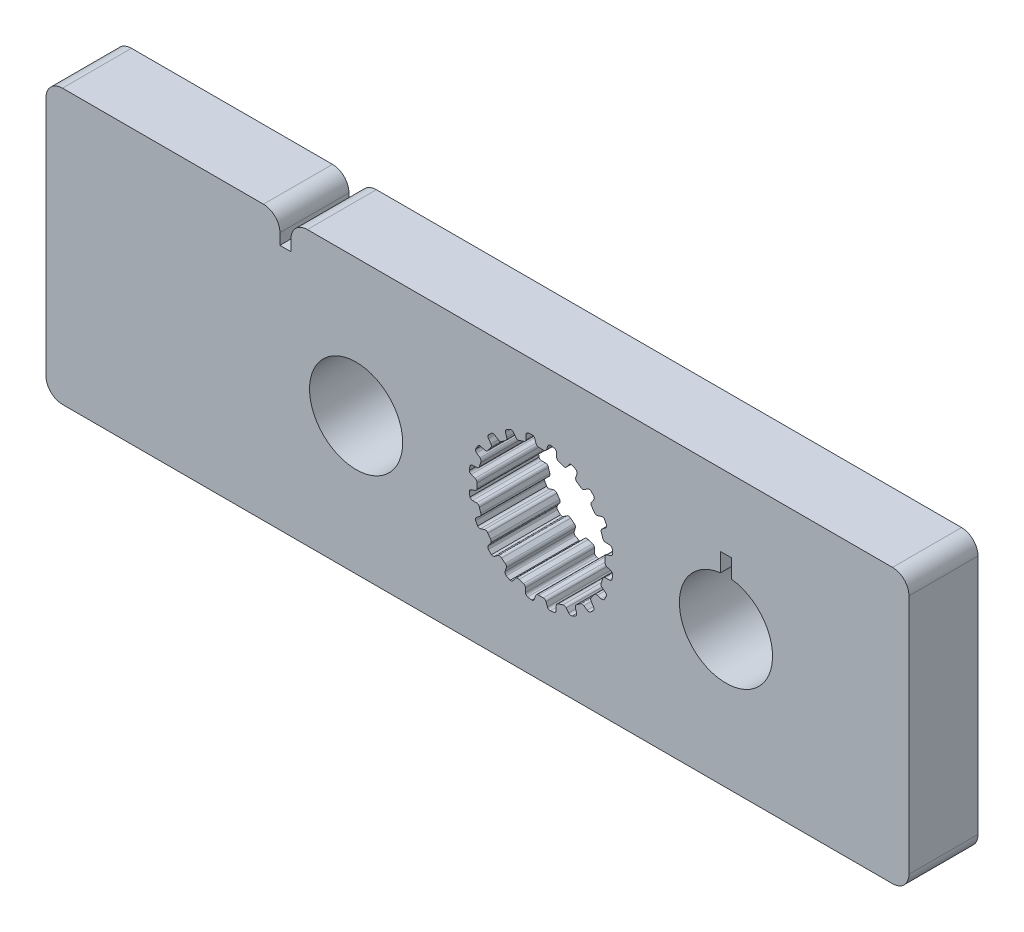
from build123d import *

# Parameters (mm, degrees)
SKETCH1_W           = 40.005
SKETCH1_H           = 12.7
SKETCH1_R           = 2.159
BOSS_EXTRUDE1_DEPTH = 1.6002
SKETCH2_W           = 0.508
SKETCH2_H           = 1.27
CUT_EXTRUDE1_DEPTH  = 3.2004
FILLET1_R           = 0.762


with BuildPart() as part:
    # Sketch1 → Boss-Extrude1 (new body, symmetric)
    with BuildSketch(Plane.XY):
        with Locations((-2.9464, 0)):
            Rectangle(SKETCH1_W, SKETCH1_H)
        with Locations((-8.5725, 0)):
            Circle(SKETCH1_R, mode=Mode.SUBTRACT)
        with Locations((8.5725, 0)):
            Circle(SKETCH1_R, mode=Mode.SUBTRACT)
        with BuildLine():
            Line((-0.106949245, 2.969874934), (0.106949245, 2.969874934))
            ThreePointArc((0.106949245, 2.969874934), (0.196343213, 2.986924176), (0.253739238, 3.057547504))
            Line((0.253739238, 3.057547504), (0.315888147, 3.237526941))
            ThreePointArc((0.315888147, 3.237526941), (0.359032156, 3.298322911), (0.4281449, 3.326269005))
            Line((0.4281449, 3.326269005), (0.620027588, 3.2937547))
            ThreePointArc((0.620027588, 3.2937547), (0.689621142, 3.24802576), (0.718272212, 3.169836791))
            Line((0.718272212, 3.169836791), (0.724389167, 2.979527391))
            ThreePointArc((0.724389167, 2.979527391), (0.750934762, 2.9040661), (0.816027049, 2.857568043))
            Line((0.816027049, 2.857568043), (1.019456602, 2.791469774))
            ThreePointArc((1.019456602, 2.791469774), (1.109743823, 2.780060312), (1.186154496, 2.829490741))
            Line((1.186154496, 2.829490741), (1.300878326, 2.981456288))
            ThreePointArc((1.300878326, 2.981456288), (1.360697704, 3.02594446), (1.435063648, 3.031165762))
            Line((1.435063648, 3.031165762), (1.607507455, 2.940947809))
            ThreePointArc((1.607507455, 2.940947809), (1.659563839, 2.875951412), (1.662650905, 2.792735615))
            Line((1.662650905, 2.792735615), (1.609659636, 2.609850378))
            ThreePointArc((1.609659636, 2.609850378), (1.611587176, 2.529879385), (1.659124931, 2.465542482))
            Line((1.659124931, 2.465542482), (1.832172444, 2.339816104))
            ThreePointArc((1.832172444, 2.339816104), (1.914514976, 2.301064775), (2.002460687, 2.32446371))
            Line((2.002460687, 2.32446371), (2.158529469, 2.433539921))
            ThreePointArc((2.158529469, 2.433539921), (2.229168681, 2.457365482), (2.301508367, 2.439350895))
            Line((2.301508367, 2.439350895), (2.437633293, 2.300260456))
            ThreePointArc((2.437633293, 2.300260456), (2.467056864, 2.222358901), (2.444277744, 2.14226202))
            Line((2.444277744, 2.14226202), (2.337365406, 1.984703026))
            ThreePointArc((2.337365406, 1.984703026), (2.314486209, 1.908050449), (2.339816104, 1.832172444))
            Line((2.339816104, 1.832172444), (2.465542482, 1.659124931))
            ThreePointArc((2.465542482, 1.659124931), (2.531880064, 1.596824985), (2.622752074, 1.591901975))
            Line((2.622752074, 1.591901975), (2.804888709, 1.64741171))
            ThreePointArc((2.804888709, 1.64741171), (2.879433095, 1.648242449), (2.942665411, 1.608755366))
            Line((2.942665411, 1.608755366), (3.0291466, 1.434407582))
            ThreePointArc((3.0291466, 1.434407582), (3.033057175, 1.351226417), (2.986641646, 1.282088892))
            Line((2.986641646, 1.282088892), (2.836273564, 1.165279113))
            ThreePointArc((2.836273564, 1.165279113), (2.790827206, 1.099448241), (2.791469774, 1.019456602))
            Line((2.791469774, 1.019456602), (2.857568043, 0.816027049))
            ThreePointArc((2.857568043, 0.816027049), (2.901407091, 0.736276839), (2.986310214, 0.703513784))
            Line((2.986310214, 0.703513784), (3.1766859, 0.700023363))
            ThreePointArc((3.1766859, 0.700023363), (3.247838536, 0.677777961), (3.295773863, 0.620683653))
            Line((3.295773863, 0.620683653), (3.324145932, 0.4281449))
            ThreePointArc((3.324145932, 0.4281449), (3.302160717, 0.347826477), (3.236652255, 0.29641597))
            Line((3.236652255, 0.29641597), (3.057547504, 0.231789562))
            ThreePointArc((3.057547504, 0.231789562), (2.993982591, 0.183224379), (2.969874934, 0.106949245))
            Line((2.969874934, 0.106949245), (2.969874934, -0.106949245))
            ThreePointArc((2.969874934, -0.106949245), (2.986924176, -0.196343213), (3.057547504, -0.253739238))
            Line((3.057547504, -0.253739238), (3.237526941, -0.315888147))
            ThreePointArc((3.237526941, -0.315888147), (3.298322911, -0.359032156), (3.326269005, -0.4281449))
            Line((3.326269005, -0.4281449), (3.2937547, -0.620027588))
            ThreePointArc((3.2937547, -0.620027588), (3.24802576, -0.689621142), (3.169836791, -0.718272212))
            Line((3.169836791, -0.718272212), (2.979527391, -0.724389167))
            ThreePointArc((2.979527391, -0.724389167), (2.9040661, -0.750934762), (2.857568043, -0.816027049))
            Line((2.857568043, -0.816027049), (2.791469774, -1.019456602))
            ThreePointArc((2.791469774, -1.019456602), (2.780060312, -1.109743823), (2.829490741, -1.186154496))
            Line((2.829490741, -1.186154496), (2.981456288, -1.300878326))
            ThreePointArc((2.981456288, -1.300878326), (3.02594446, -1.360697704), (3.031165762, -1.435063648))
            Line((3.031165762, -1.435063648), (2.940947809, -1.607507455))
            ThreePointArc((2.940947809, -1.607507455), (2.875951412, -1.659563839), (2.792735615, -1.662650905))
            Line((2.792735615, -1.662650905), (2.609850378, -1.609659636))
            ThreePointArc((2.609850378, -1.609659636), (2.529879385, -1.611587176), (2.465542482, -1.659124931))
            Line((2.465542482, -1.659124931), (2.339816104, -1.832172444))
            ThreePointArc((2.339816104, -1.832172444), (2.301064775, -1.914514976), (2.32446371, -2.002460687))
            Line((2.32446371, -2.002460687), (2.433539921, -2.158529469))
            ThreePointArc((2.433539921, -2.158529469), (2.457365482, -2.229168681), (2.439350895, -2.301508367))
            Line((2.439350895, -2.301508367), (2.300260456, -2.437633293))
            ThreePointArc((2.300260456, -2.437633293), (2.222358901, -2.467056864), (2.14226202, -2.444277744))
            Line((2.14226202, -2.444277744), (1.984703026, -2.337365406))
            ThreePointArc((1.984703026, -2.337365406), (1.908050449, -2.314486209), (1.832172444, -2.339816104))
            Line((1.832172444, -2.339816104), (1.659124931, -2.465542482))
            ThreePointArc((1.659124931, -2.465542482), (1.596824985, -2.531880064), (1.591901975, -2.622752074))
            Line((1.591901975, -2.622752074), (1.64741171, -2.804888709))
            ThreePointArc((1.64741171, -2.804888709), (1.648242449, -2.879433095), (1.608755366, -2.942665411))
            Line((1.608755366, -2.942665411), (1.434407582, -3.0291466))
            ThreePointArc((1.434407582, -3.0291466), (1.351226417, -3.033057175), (1.282088892, -2.986641646))
            Line((1.282088892, -2.986641646), (1.165279113, -2.836273564))
            ThreePointArc((1.165279113, -2.836273564), (1.099448241, -2.790827206), (1.019456602, -2.791469774))
            Line((1.019456602, -2.791469774), (0.816027049, -2.857568043))
            ThreePointArc((0.816027049, -2.857568043), (0.736276839, -2.901407091), (0.703513784, -2.986310214))
            Line((0.703513784, -2.986310214), (0.700023363, -3.1766859))
            ThreePointArc((0.700023363, -3.1766859), (0.677777961, -3.247838536), (0.620683653, -3.295773863))
            Line((0.620683653, -3.295773863), (0.4281449, -3.324145932))
            ThreePointArc((0.4281449, -3.324145932), (0.347826477, -3.302160717), (0.29641597, -3.236652255))
            Line((0.29641597, -3.236652255), (0.231789562, -3.057547504))
            ThreePointArc((0.231789562, -3.057547504), (0.183224379, -2.993982591), (0.106949245, -2.969874934))
            Line((0.106949245, -2.969874934), (-0.106949245, -2.969874934))
            ThreePointArc((-0.106949245, -2.969874934), (-0.196343213, -2.986924176), (-0.253739238, -3.057547504))
            Line((-0.253739238, -3.057547504), (-0.315888147, -3.237526941))
            ThreePointArc((-0.315888147, -3.237526941), (-0.359032156, -3.298322911), (-0.4281449, -3.326269005))
            Line((-0.4281449, -3.326269005), (-0.620027588, -3.2937547))
            ThreePointArc((-0.620027588, -3.2937547), (-0.689621142, -3.24802576), (-0.718272212, -3.169836791))
            Line((-0.718272212, -3.169836791), (-0.724389167, -2.979527391))
            ThreePointArc((-0.724389167, -2.979527391), (-0.750934762, -2.9040661), (-0.816027049, -2.857568043))
            Line((-0.816027049, -2.857568043), (-1.019456602, -2.791469774))
            ThreePointArc((-1.019456602, -2.791469774), (-1.109743823, -2.780060312), (-1.186154496, -2.829490741))
            Line((-1.186154496, -2.829490741), (-1.300878326, -2.981456288))
            ThreePointArc((-1.300878326, -2.981456288), (-1.360697704, -3.02594446), (-1.435063648, -3.031165762))
            Line((-1.435063648, -3.031165762), (-1.607507455, -2.940947809))
            ThreePointArc((-1.607507455, -2.940947809), (-1.659563839, -2.875951412), (-1.662650905, -2.792735615))
            Line((-1.662650905, -2.792735615), (-1.609659636, -2.609850378))
            ThreePointArc((-1.609659636, -2.609850378), (-1.611587176, -2.529879385), (-1.659124931, -2.465542482))
            Line((-1.659124931, -2.465542482), (-1.832172444, -2.339816104))
            ThreePointArc((-1.832172444, -2.339816104), (-1.914514976, -2.301064775), (-2.002460687, -2.32446371))
            Line((-2.002460687, -2.32446371), (-2.158529469, -2.433539921))
            ThreePointArc((-2.158529469, -2.433539921), (-2.229168681, -2.457365482), (-2.301508367, -2.439350895))
            Line((-2.301508367, -2.439350895), (-2.437633293, -2.300260456))
            ThreePointArc((-2.437633293, -2.300260456), (-2.467056864, -2.222358901), (-2.444277744, -2.14226202))
            Line((-2.444277744, -2.14226202), (-2.337365406, -1.984703026))
            ThreePointArc((-2.337365406, -1.984703026), (-2.314486209, -1.908050449), (-2.339816104, -1.832172444))
            Line((-2.339816104, -1.832172444), (-2.465542482, -1.659124931))
            ThreePointArc((-2.465542482, -1.659124931), (-2.531880064, -1.596824985), (-2.622752074, -1.591901975))
            Line((-2.622752074, -1.591901975), (-2.804888709, -1.64741171))
            ThreePointArc((-2.804888709, -1.64741171), (-2.879433095, -1.648242449), (-2.942665411, -1.608755366))
            Line((-2.942665411, -1.608755366), (-3.0291466, -1.434407582))
            ThreePointArc((-3.0291466, -1.434407582), (-3.033057175, -1.351226417), (-2.986641646, -1.282088892))
            Line((-2.986641646, -1.282088892), (-2.836273564, -1.165279113))
            ThreePointArc((-2.836273564, -1.165279113), (-2.790827206, -1.099448241), (-2.791469774, -1.019456602))
            Line((-2.791469774, -1.019456602), (-2.857568043, -0.816027049))
            ThreePointArc((-2.857568043, -0.816027049), (-2.901407091, -0.736276839), (-2.986310214, -0.703513784))
            Line((-2.986310214, -0.703513784), (-3.1766859, -0.700023363))
            ThreePointArc((-3.1766859, -0.700023363), (-3.247838536, -0.677777961), (-3.295773863, -0.620683653))
            Line((-3.295773863, -0.620683653), (-3.324145932, -0.4281449))
            ThreePointArc((-3.324145932, -0.4281449), (-3.302160717, -0.347826477), (-3.236652255, -0.29641597))
            Line((-3.236652255, -0.29641597), (-3.057547504, -0.231789562))
            ThreePointArc((-3.057547504, -0.231789562), (-2.993982591, -0.183224379), (-2.969874934, -0.106949245))
            Line((-2.969874934, -0.106949245), (-2.969874934, 0.106949245))
            ThreePointArc((-2.969874934, 0.106949245), (-2.986924176, 0.196343213), (-3.057547504, 0.253739238))
            Line((-3.057547504, 0.253739238), (-3.237526941, 0.315888147))
            ThreePointArc((-3.237526941, 0.315888147), (-3.298322911, 0.359032156), (-3.326269005, 0.4281449))
            Line((-3.326269005, 0.4281449), (-3.2937547, 0.620027588))
            ThreePointArc((-3.2937547, 0.620027588), (-3.24802576, 0.689621142), (-3.169836791, 0.718272212))
            Line((-3.169836791, 0.718272212), (-2.979527391, 0.724389167))
            ThreePointArc((-2.979527391, 0.724389167), (-2.9040661, 0.750934762), (-2.857568043, 0.816027049))
            Line((-2.857568043, 0.816027049), (-2.791469774, 1.019456602))
            ThreePointArc((-2.791469774, 1.019456602), (-2.780060312, 1.109743823), (-2.829490741, 1.186154496))
            Line((-2.829490741, 1.186154496), (-2.981456288, 1.300878326))
            ThreePointArc((-2.981456288, 1.300878326), (-3.02594446, 1.360697704), (-3.031165762, 1.435063648))
            Line((-3.031165762, 1.435063648), (-2.940947809, 1.607507455))
            ThreePointArc((-2.940947809, 1.607507455), (-2.875951412, 1.659563839), (-2.792735615, 1.662650905))
            Line((-2.792735615, 1.662650905), (-2.609850378, 1.609659636))
            ThreePointArc((-2.609850378, 1.609659636), (-2.529879385, 1.611587176), (-2.465542482, 1.659124931))
            Line((-2.465542482, 1.659124931), (-2.339816104, 1.832172444))
            ThreePointArc((-2.339816104, 1.832172444), (-2.301064775, 1.914514976), (-2.32446371, 2.002460687))
            Line((-2.32446371, 2.002460687), (-2.433539921, 2.158529469))
            ThreePointArc((-2.433539921, 2.158529469), (-2.457365482, 2.229168681), (-2.439350895, 2.301508367))
            Line((-2.439350895, 2.301508367), (-2.300260456, 2.437633293))
            ThreePointArc((-2.300260456, 2.437633293), (-2.222358901, 2.467056864), (-2.14226202, 2.444277744))
            Line((-2.14226202, 2.444277744), (-1.984703026, 2.337365406))
            ThreePointArc((-1.984703026, 2.337365406), (-1.908050449, 2.314486209), (-1.832172444, 2.339816104))
            Line((-1.832172444, 2.339816104), (-1.659124931, 2.465542482))
            ThreePointArc((-1.659124931, 2.465542482), (-1.596824985, 2.531880064), (-1.591901975, 2.622752074))
            Line((-1.591901975, 2.622752074), (-1.64741171, 2.804888709))
            ThreePointArc((-1.64741171, 2.804888709), (-1.648242449, 2.879433095), (-1.608755366, 2.942665411))
            Line((-1.608755366, 2.942665411), (-1.434407582, 3.0291466))
            ThreePointArc((-1.434407582, 3.0291466), (-1.351226417, 3.033057175), (-1.282088892, 2.986641646))
            Line((-1.282088892, 2.986641646), (-1.165279113, 2.836273564))
            ThreePointArc((-1.165279113, 2.836273564), (-1.099448241, 2.790827206), (-1.019456602, 2.791469774))
            Line((-1.019456602, 2.791469774), (-0.816027049, 2.857568043))
            ThreePointArc((-0.816027049, 2.857568043), (-0.736276839, 2.901407091), (-0.703513784, 2.986310214))
            Line((-0.703513784, 2.986310214), (-0.700023363, 3.1766859))
            ThreePointArc((-0.700023363, 3.1766859), (-0.677777961, 3.247838536), (-0.620683653, 3.295773863))
            Line((-0.620683653, 3.295773863), (-0.4281449, 3.324145932))
            ThreePointArc((-0.4281449, 3.324145932), (-0.347826477, 3.302160717), (-0.29641597, 3.236652255))
            Line((-0.29641597, 3.236652255), (-0.231789562, 3.057547504))
            ThreePointArc((-0.231789562, 3.057547504), (-0.183224379, 2.993982591), (-0.106949245, 2.969874934))
        make_face(mode=Mode.SUBTRACT)
    extrude(amount=BOSS_EXTRUDE1_DEPTH, both=True)

    # Sketch2 → Cut-Extrude1 (cut)
    with BuildSketch(Plane.XY.offset(1.6002)):
        with Locations((-11.851037851, 5.715)):
            Rectangle(SKETCH2_W, SKETCH2_H)
        with Locations((8.5725, 2.36728)):
            Rectangle(SKETCH2_W, SKETCH2_H)
    extrude(amount=-CUT_EXTRUDE1_DEPTH, mode=Mode.SUBTRACT)

    # Fillet1
    fillet1_edges = [part.edges().sort_by_distance(p)[0] for p in [
        (-12.105037851, 6.35, 0),
        (-11.597037851, 6.35, 0),
        (-22.9489, 6.35, 0),
        (17.0561, 6.35, 0),
        (17.0561, -6.35, 0),
        (-22.9489, -6.35, 0),
    ]]
    fillet(fillet1_edges, radius=FILLET1_R)


solid = part.part
